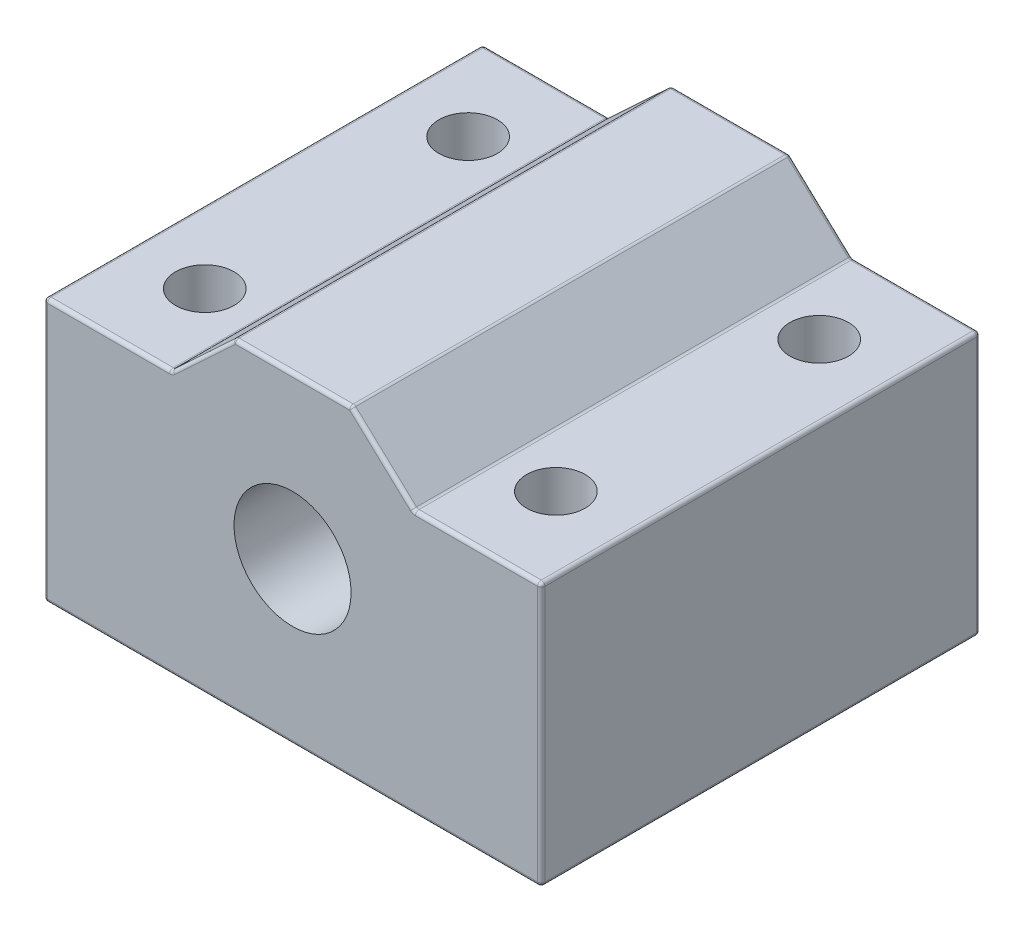
from build123d import *

# Parameters (mm, degrees)
SKETCH1_R           = 4
BOSS_EXTRUDE1_DEPTH = 15
CUT_EXTRUDE1_REACH  = 24
SKETCH2_R           = 2
FILLET1_R           = 0.25


with BuildPart() as part:
    # Sketch1 → Boss-Extrude1 (new body, symmetric)
    with BuildSketch(Plane.XY):
        Polygon((17, -11), (-17, -11), (-17, 7), (-8.3, 7), (-4, 11), (4, 11), (8.3, 7), (17, 7), align=None)
        Circle(SKETCH1_R, mode=Mode.SUBTRACT)
    extrude(amount=BOSS_EXTRUDE1_DEPTH, both=True)

    # Sketch2 → Cut-Extrude1 (cut, up to next)
    with BuildSketch(Plane.XZ.offset(11), mode=Mode.PRIVATE) as cut_extrude1_sk1:
        with Locations((12, 9)):
            Circle(SKETCH2_R)
    cut_extrude1_tool1 = extrude(cut_extrude1_sk1.sketch, amount=-CUT_EXTRUDE1_REACH, mode=Mode.PRIVATE) & part.part
    add(cut_extrude1_tool1.solids().sort_by_distance((12, -11, 9))[0], mode=Mode.SUBTRACT)
    # Sketch2 → Cut-Extrude1 (cut, up to next)
    with BuildSketch(Plane.XZ.offset(11), mode=Mode.PRIVATE) as cut_extrude1_sk2:
        with Locations((-12, 9)):
            Circle(SKETCH2_R)
    cut_extrude1_tool2 = extrude(cut_extrude1_sk2.sketch, amount=-CUT_EXTRUDE1_REACH, mode=Mode.PRIVATE) & part.part
    add(cut_extrude1_tool2.solids().sort_by_distance((-12, -11, 9))[0], mode=Mode.SUBTRACT)
    # Sketch2 → Cut-Extrude1 (cut, up to next)
    with BuildSketch(Plane.XZ.offset(11), mode=Mode.PRIVATE) as cut_extrude1_sk3:
        with Locations((12, -9)):
            Circle(SKETCH2_R)
    cut_extrude1_tool3 = extrude(cut_extrude1_sk3.sketch, amount=-CUT_EXTRUDE1_REACH, mode=Mode.PRIVATE) & part.part
    add(cut_extrude1_tool3.solids().sort_by_distance((12, -11, -9))[0], mode=Mode.SUBTRACT)
    # Sketch2 → Cut-Extrude1 (cut, up to next)
    with BuildSketch(Plane.XZ.offset(11), mode=Mode.PRIVATE) as cut_extrude1_sk4:
        with Locations((-12, -9)):
            Circle(SKETCH2_R)
    cut_extrude1_tool4 = extrude(cut_extrude1_sk4.sketch, amount=-CUT_EXTRUDE1_REACH, mode=Mode.PRIVATE) & part.part
    add(cut_extrude1_tool4.solids().sort_by_distance((-12, -11, -9))[0], mode=Mode.SUBTRACT)

    # Fillet1
    fillet1_edges = [part.edges().sort_by_distance(p)[0] for p in [
        (0, 11, -15),
        (6.15, 9, -15),
        (12.65, 7, -15),
        (17, -2, -15),
        (6.15, 9, 15),
        (17, -11, 0),
        (-17, -11, 0),
        (-17, 7, 0),
        (-8.3, 7, 0),
        (-4, 11, 0),
        (4, 11, 0),
        (8.3, 7, 0),
        (17, 7, 0),
        (0, 11, 15),
        (-6.15, 9, 15),
        (-12.65, 7, 15),
        (-17, -2, 15),
        (0, -11, 15),
        (17, -2, 15),
        (0, -11, -15),
        (12.65, 7, 15),
        (-17, -2, -15),
        (-12.65, 7, -15),
        (-6.15, 9, -15),
    ]]
    fillet(fillet1_edges, radius=FILLET1_R)


solid = part.part
